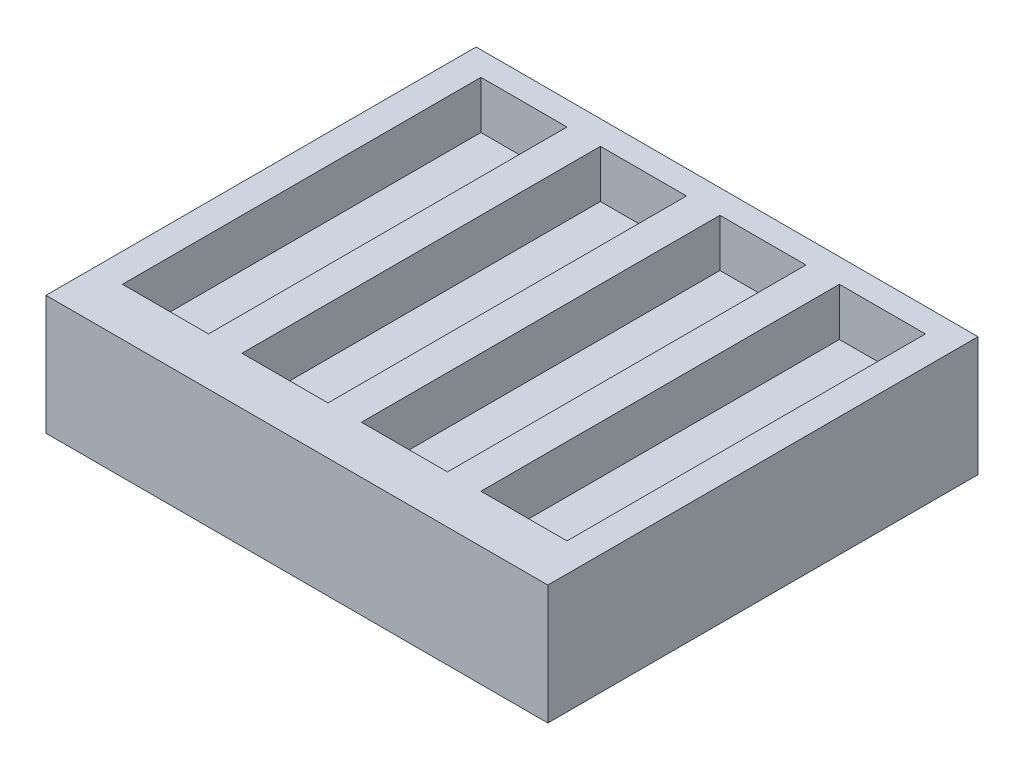
from build123d import *

# Parameters (mm, degrees)
SKETCH1_W           = 105
SKETCH1_H           = 90
BOSS_EXTRUDE1_DEPTH = 25
SKETCH2_W           = 18
SKETCH2_H           = 75
CUT_EXTRUDE1_DEPTH  = 10


with BuildPart() as part:
    # Sketch1 → Boss-Extrude1 (new body)
    with BuildSketch(Plane(origin=(0, 0, 0), x_dir=(1, 0, 0), z_dir=(0, 1, 0))):
        Rectangle(SKETCH1_W, SKETCH1_H)
    extrude(amount=BOSS_EXTRUDE1_DEPTH)

    # Sketch2 → Cut-Extrude1 (cut)
    with BuildSketch(Plane(origin=(0, 25, 0), x_dir=(1, 0, 0), z_dir=(0, 1, 0))):
        with Locations((-37.5, 2.5)):
            Rectangle(SKETCH2_W, SKETCH2_H)
        with Locations((-12.5, 2.5)):
            Rectangle(SKETCH2_W, SKETCH2_H)
        with Locations((12.5, 2.5)):
            Rectangle(SKETCH2_W, SKETCH2_H)
        with Locations((37.5, 2.5)):
            Rectangle(SKETCH2_W, SKETCH2_H)
    extrude(amount=-CUT_EXTRUDE1_DEPTH, mode=Mode.SUBTRACT)


solid = part.part
